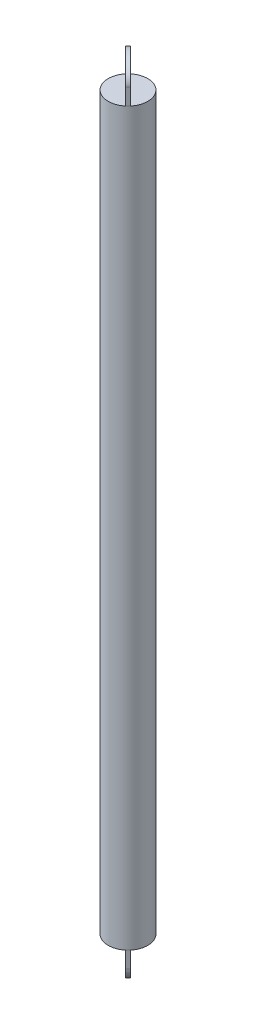
from build123d import *

# Parameters (mm, degrees)
SKETCH1_R           = 6
BOSS_EXTRUDE2_DEPTH = 111
BOSS_EXTRUDE4_DEPTH = 0.5


with BuildPart() as part:
    # Sketch1 → Boss-Extrude2 (new body)
    with BuildSketch(Plane(origin=(0, 0, 0), x_dir=(1, 0, 0), z_dir=(0, 1, 0))):
        Circle(SKETCH1_R)
    boss_extrude2 = extrude(amount=BOSS_EXTRUDE2_DEPTH)

    # Sketch4 → Boss-Extrude4 (add, symmetric)
    with BuildSketch(Plane(origin=(0, 0, 0), x_dir=(-0.7071067811865477, 0, -0.7071067811865475), z_dir=(0.7071067811865475, 0, -0.7071067811865477))):
        with BuildLine():
            Line((5, -5), (5, 0))
            Line((5, 0), (6, 0))
            Line((6, 0), (6, -5))
            add(Edge.make_bspline(
                [(-6, -5), (-6, -10), (0, -10), (6, -10), (6, -5)],
                knots=[3.141592654, 3.141592654, 3.141592654, 4.71238898, 4.71238898, 6.283185307, 6.283185307, 6.283185307], degree=2, weights=[1, 0.707106781, 1, 0.707106781, 1]))
            Line((-6, -5), (-6, 0))
            Line((-6, 0), (-5, 0))
            Line((-5, 0), (-5, -5))
            add(Edge.make_bspline(
                [(-5, -5), (-5, -9), (0, -9), (5, -9), (5, -5)],
                knots=[3.141592654, 3.141592654, 3.141592654, 4.71238898, 4.71238898, 6.283185307, 6.283185307, 6.283185307], degree=2, weights=[1, 0.707106781, 1, 0.707106781, 1]))
        make_face()
    boss_extrude4 = extrude(amount=BOSS_EXTRUDE4_DEPTH, both=True)

    # Mirror1: Boss-Extrude2, Boss-Extrude4 across plane
    add(boss_extrude2.mirror(Plane.ZX.offset(111)))
    add(boss_extrude4.mirror(Plane.ZX.offset(111)))


solid = part.part
